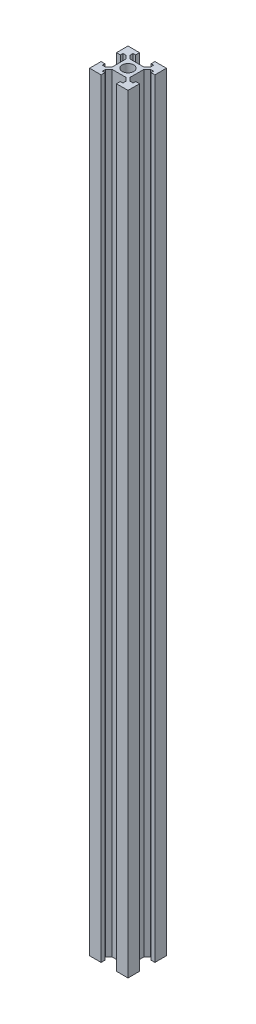
from build123d import *

# Parameters (mm, degrees)
SKETCH1_R           = 9
BOSS_EXTRUDE1_DEPTH = 1200


with BuildPart() as part:
    # Sketch1 → Boss-Extrude1 (new body)
    with BuildSketch(Plane(origin=(0, 0, 0), x_dir=(1, 0, 0), z_dir=(0, 1, 0))):
        Polygon((-30, 30), (-12, 30), (-12, 24), (-16, 24), (-16, 19), (-11, 14), (11, 14), (16, 19), (16, 24), (12, 24), (12, 30), (30, 30), (30, 12), (24, 12), (24, 16), (19, 16), (14, 11), (14, -11), (19, -16), (24, -16), (24, -12), (30, -12), (30, -30), (12, -30), (12, -24), (16, -24), (16, -19), (11, -14), (-11, -14), (-16, -19), (-16, -24), (-12, -24), (-12, -30), (-30, -30), (-30, -12), (-24, -12), (-24, -16), (-19, -16), (-14, -11), (-14, 11), (-19, 16), (-24, 16), (-24, 12), (-30, 12), align=None)
        Circle(SKETCH1_R, mode=Mode.SUBTRACT)
    extrude(amount=BOSS_EXTRUDE1_DEPTH)


solid = part.part
